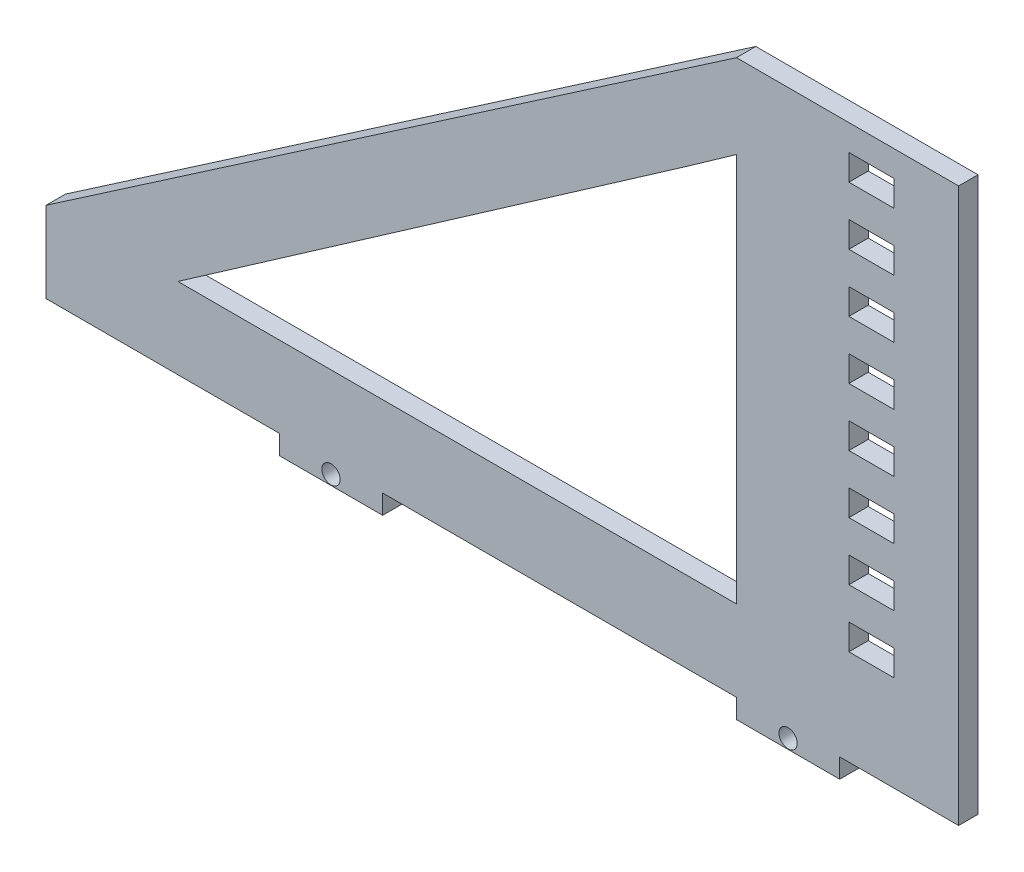
from build123d import *

# Parameters (mm, degrees)
SKETCH1_R           = 1.42
SKETCH1_W           = 7
SKETCH1_H           = 4
BOSS_EXTRUDE2_DEPTH = 3


with BuildPart() as part:
    # Sketch1 → Boss-Extrude2 (new body)
    with BuildSketch(Plane.XY):
        Polygon((36.149381, 0), (36.149381, -3), (52.149381, -3), (52.149381, 0), (106.959381, 0), (106.959381, -3), (122.959381, -3), (122.959381, 0), (141.38, 0), (141.38, 27.105503225), (141.38, 85.806519795), (140.170833607, 85.806519795), (122.959381, 85.806519795), (106.959381, 85.806519795), (0, 12.520138185), (0, 0), align=None)
        with Locations((44.149381, -1.5)):
            Circle(SKETCH1_R, mode=Mode.SUBTRACT)
        with Locations((114.959381, -1.5)):
            Circle(SKETCH1_R, mode=Mode.SUBTRACT)
        Polygon((20.433228311, 12.520138185), (99.128706317, 67.278357703), (106.959381, 72.806519795), (106.959381, 12.520138185), (99.128706317, 12.520138185), align=None, mode=Mode.SUBTRACT)
        with Locations((127.88, 70.806519795)):
            Rectangle(SKETCH1_W, SKETCH1_H, mode=Mode.SUBTRACT)
        with Locations((127.88, 79.806519795)):
            Rectangle(SKETCH1_W, SKETCH1_H, mode=Mode.SUBTRACT)
        with Locations((127.88, 61.806519795)):
            Rectangle(SKETCH1_W, SKETCH1_H, mode=Mode.SUBTRACT)
        with Locations((127.88, 52.806519795)):
            Rectangle(SKETCH1_W, SKETCH1_H, mode=Mode.SUBTRACT)
        with Locations((127.88, 43.806519795)):
            Rectangle(SKETCH1_W, SKETCH1_H, mode=Mode.SUBTRACT)
        with Locations((127.88, 34.806519795)):
            Rectangle(SKETCH1_W, SKETCH1_H, mode=Mode.SUBTRACT)
        with Locations((127.88, 25.806519795)):
            Rectangle(SKETCH1_W, SKETCH1_H, mode=Mode.SUBTRACT)
        with Locations((127.88, 16.806519795)):
            Rectangle(SKETCH1_W, SKETCH1_H, mode=Mode.SUBTRACT)
    extrude(amount=BOSS_EXTRUDE2_DEPTH)


solid = part.part
